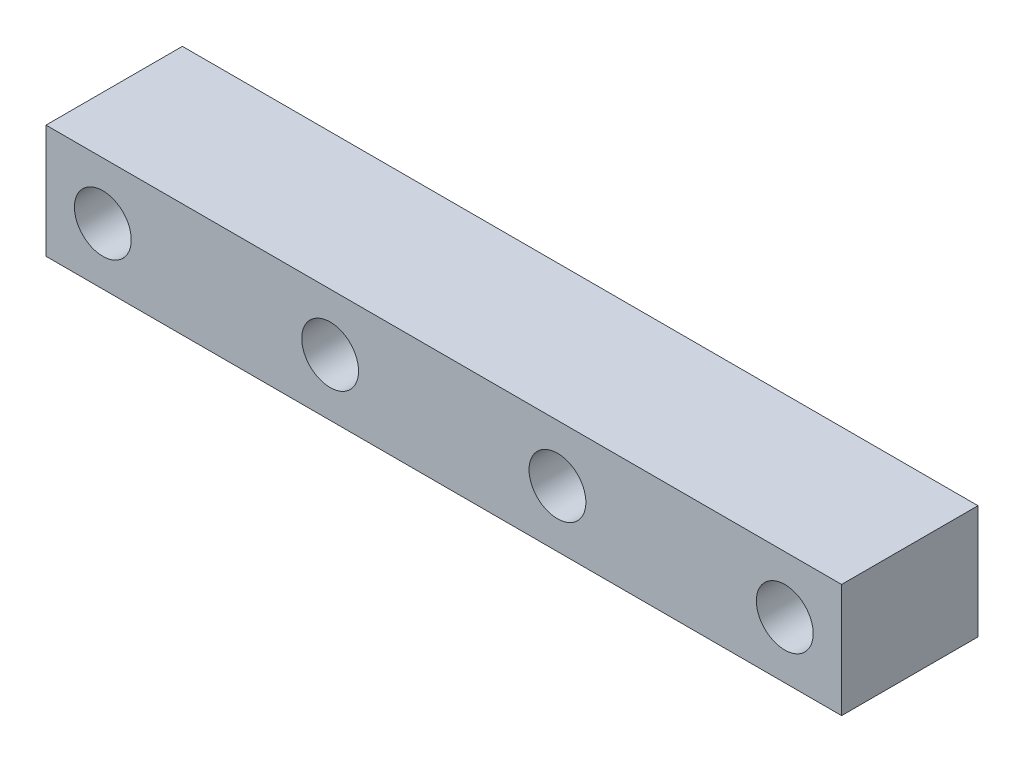
from build123d import *

# Parameters (mm, degrees)
SKETCH2_W           = 44.45
SKETCH2_H           = 6.35
BOSS_EXTRUDE1_DEPTH = 7.62
SKETCH4_R           = 1.5875
CUT_EXTRUDE2_DEPTH  = 8.62


with BuildPart() as part:
    # Sketch2 → Boss-Extrude1 (new body)
    with BuildSketch(Plane.XY):
        Rectangle(SKETCH2_W, SKETCH2_H)
    extrude(amount=BOSS_EXTRUDE1_DEPTH)

    # Sketch4 → Cut-Extrude2 (cut, through all)
    with BuildSketch(Plane(origin=(0, 0, 0), x_dir=(-1, 0, 0), z_dir=(0, 0, -1))):
        with Locations((-6.35, 0)):
            Circle(SKETCH4_R)
        with Locations((-19.05, 0)):
            Circle(SKETCH4_R)
    cut_extrude2 = extrude(amount=-CUT_EXTRUDE2_DEPTH, mode=Mode.SUBTRACT)

    # Mirror2: Cut-Extrude2 across plane
    add(cut_extrude2.mirror(Plane(origin=(0, 0, 0), x_dir=(0, 0, 1), z_dir=(1, 0, 0))), mode=Mode.SUBTRACT)


solid = part.part
